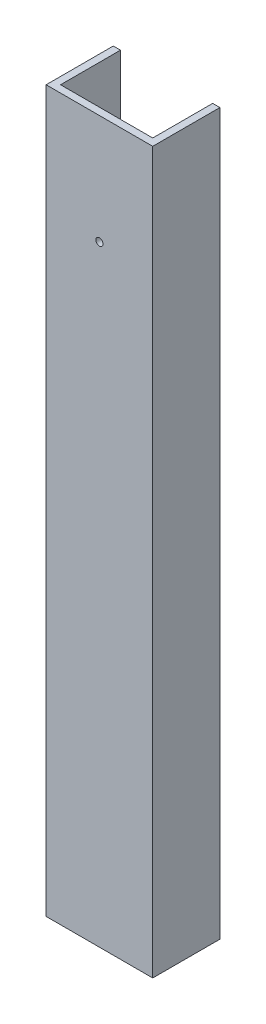
from build123d import *

# Parameters (mm, degrees)
CROQUIS1_W              = 37
CROQUIS1_H              = 23.3
SALIENTE_EXTRUIR1_DEPTH = 250
CROQUIS2_W              = 32
CROQUIS2_H              = 20.8
CORTAR_EXTRUIR1_DEPTH   = 250
CROQUIS3_R              = 1.25
CORTAR_EXTRUIR2_DEPTH   = 250


with BuildPart() as part:
    # Croquis1 → Saliente-Extruir1 (new body)
    with BuildSketch(Plane(origin=(0, 0, 0), x_dir=(1, 0, 0), z_dir=(0, 1, 0))):
        Rectangle(CROQUIS1_W, CROQUIS1_H)
    extrude(amount=SALIENTE_EXTRUIR1_DEPTH)

    # Croquis2 → Cortar-Extruir1 (cut)
    with BuildSketch(Plane(origin=(0, 250, 0), x_dir=(1, 0, 0), z_dir=(0, 1, 0))):
        with Locations((0, 1.25)):
            Rectangle(CROQUIS2_W, CROQUIS2_H)
    extrude(amount=-CORTAR_EXTRUIR1_DEPTH, mode=Mode.SUBTRACT)

    # Croquis3 → Cortar-Extruir2 (cut)
    with BuildSketch(Plane.XY.offset(11.65)):
        with Locations((0, 212)):
            Circle(CROQUIS3_R)
    extrude(amount=-CORTAR_EXTRUIR2_DEPTH, mode=Mode.SUBTRACT)


solid = part.part
